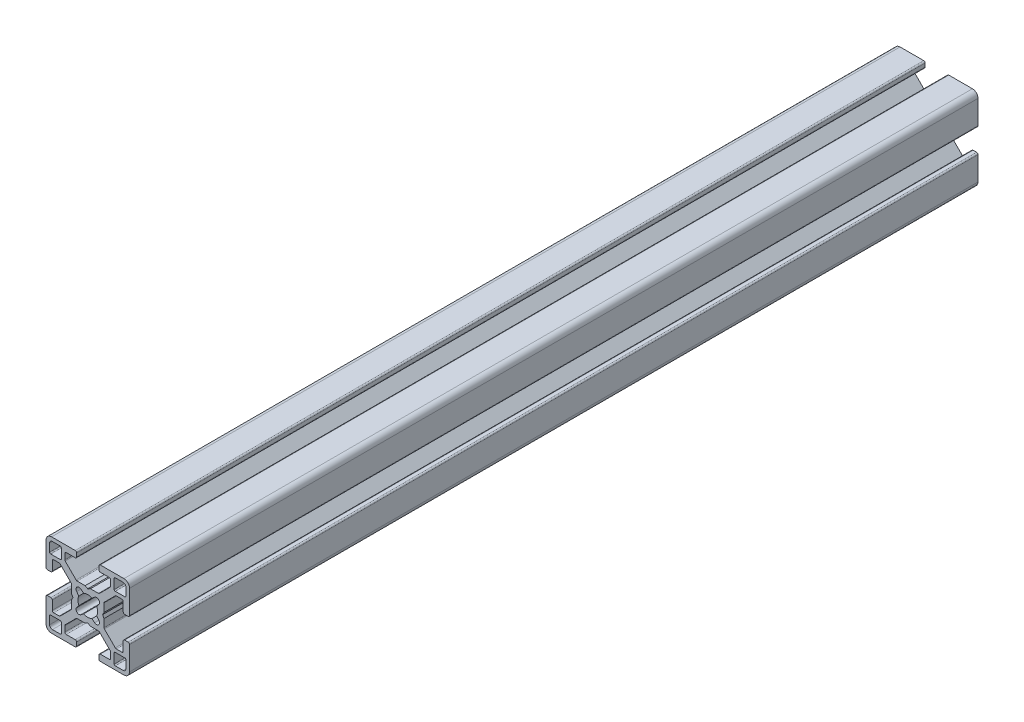
from build123d import *

# Parameters (mm, degrees)
EXTRUDE1_DEPTH = 304.8


with BuildPart() as part:
    # Sketch1 → Extrude1 (new body)
    with BuildSketch(Plane.XY):
        with BuildLine():
            Line((12.74247465, -4.5), (12.74247465, -7.732519321))
            ThreePointArc((12.74247465, -7.732519321), (12.602449697, -8.097296796), (12.242781236, -8.249967))
            Line((12.242781236, -8.249967), (10.260188032, -8.249967))
            ThreePointArc((10.260188032, -8.249967), (10.068847082, -8.211906919), (9.906636056, -8.103520976))
            Line((9.906636056, -8.103520976), (5.981117769, -4.178002689))
            ThreePointArc((5.981117769, -4.178002689), (5.872731827, -4.015791664), (5.834671745, -3.824450713))
            Line((5.834671745, -3.824450713), (5.834671745, -1.01249595))
            Line((5.834671745, -1.01249595), (5.324673785, -0.06249975))
            Line((5.324673785, -0.06249975), (5.834671745, 0.88749645))
            Line((5.834671745, 0.88749645), (5.834671745, 3.824450713))
            ThreePointArc((5.834671745, 3.824450713), (5.872731827, 4.015791664), (5.981117769, 4.178002689))
            Line((5.981117769, 4.178002689), (9.906636056, 8.103520976))
            ThreePointArc((9.906636056, 8.103520976), (10.068847082, 8.211906919), (10.260188032, 8.249967))
            Line((10.260188032, 8.249967), (12.242781236, 8.249967))
            ThreePointArc((12.242781236, 8.249967), (12.602449697, 8.097296796), (12.74247465, 7.732519321))
            Line((12.74247465, 7.732519321), (12.74247465, 4.5))
            ThreePointArc((12.74247465, 4.5), (12.88892126, 4.146446609), (13.24247465, 4))
            Line((13.24247465, 4), (14.49994, 4))
            ThreePointArc((14.49994, 4), (14.853493391, 4.146446609), (14.99994, 4.5))
            Line((14.99994, 4.5), (14.99994, 12.999948))
            ThreePointArc((14.99994, 12.999948), (14.414155906, 14.414155906), (12.999948, 14.99994))
            Line((12.999948, 14.99994), (4.5, 14.99994))
            ThreePointArc((4.5, 14.99994), (4.146446609, 14.853493391), (4, 14.49994))
            Line((4, 14.49994), (4, 13.24247465))
            ThreePointArc((4, 13.24247465), (4.146446609, 12.88892126), (4.5, 12.74247465))
            Line((4.5, 12.74247465), (7.732519321, 12.74247465))
            ThreePointArc((7.732519321, 12.74247465), (8.097296796, 12.602449697), (8.249967, 12.242781236))
            Line((8.249967, 12.242781236), (8.249967, 10.260188032))
            ThreePointArc((8.249967, 10.260188032), (8.211906919, 10.068847082), (8.103520976, 9.906636056))
            Line((8.103520976, 9.906636056), (4.178002689, 5.981117769))
            ThreePointArc((4.178002689, 5.981117769), (4.015791664, 5.872731827), (3.824450713, 5.834671745))
            Line((3.824450713, 5.834671745), (0.9499962, 5.834671745))
            Line((0.9499962, 5.834671745), (0, 5.324673785))
            Line((0, 5.324673785), (-0.9499962, 5.834671745))
            Line((-0.9499962, 5.834671745), (-3.824450713, 5.834671745))
            ThreePointArc((-3.824450713, 5.834671745), (-4.015791664, 5.872731827), (-4.178002689, 5.981117769))
            Line((-4.178002689, 5.981117769), (-8.103520976, 9.906636056))
            ThreePointArc((-8.103520976, 9.906636056), (-8.211906919, 10.068847082), (-8.249967, 10.260188032))
            Line((-8.249967, 10.260188032), (-8.249967, 12.242781236))
            ThreePointArc((-8.249967, 12.242781236), (-8.097296796, 12.602449697), (-7.732519321, 12.74247465))
            Line((-7.732519321, 12.74247465), (-4.5, 12.74247465))
            ThreePointArc((-4.5, 12.74247465), (-4.146446609, 12.88892126), (-4, 13.24247465))
            Line((-4, 13.24247465), (-4, 14.49994))
            ThreePointArc((-4, 14.49994), (-4.146446609, 14.853493391), (-4.5, 14.99994))
            Line((-4.5, 14.99994), (-12.999948, 14.99994))
            ThreePointArc((-12.999948, 14.99994), (-14.414155906, 14.414155906), (-14.99994, 12.999948))
            Line((-14.99994, 12.999948), (-14.99994, 4.5))
            ThreePointArc((-14.99994, 4.5), (-14.853493391, 4.146446609), (-14.49994, 4))
            Line((-14.49994, 4), (-13.24247465, 4))
            ThreePointArc((-13.24247465, 4), (-12.88892126, 4.146446609), (-12.74247465, 4.5))
            Line((-12.74247465, 4.5), (-12.74247465, 7.732519321))
            ThreePointArc((-12.74247465, 7.732519321), (-12.602449697, 8.097296796), (-12.242781236, 8.249967))
            Line((-12.242781236, 8.249967), (-10.260188032, 8.249967))
            ThreePointArc((-10.260188032, 8.249967), (-10.068847082, 8.211906919), (-9.906636056, 8.103520976))
            Line((-9.906636056, 8.103520976), (-5.981117769, 4.178002689))
            ThreePointArc((-5.981117769, 4.178002689), (-5.872731827, 4.015791664), (-5.834671745, 3.824450713))
            Line((-5.834671745, 3.824450713), (-5.834671745, 0.88749645))
            Line((-5.834671745, 0.88749645), (-5.324673785, -0.06249975))
            Line((-5.324673785, -0.06249975), (-5.834671745, -1.01249595))
            Line((-5.834671745, -1.01249595), (-5.834671745, -3.824450713))
            ThreePointArc((-5.834671745, -3.824450713), (-5.872731827, -4.015791664), (-5.981117769, -4.178002689))
            Line((-5.981117769, -4.178002689), (-9.906636056, -8.103520976))
            ThreePointArc((-9.906636056, -8.103520976), (-10.068847082, -8.211906919), (-10.260188032, -8.249967))
            Line((-10.260188032, -8.249967), (-12.242781236, -8.249967))
            ThreePointArc((-12.242781236, -8.249967), (-12.602449697, -8.097296796), (-12.74247465, -7.732519321))
            Line((-12.74247465, -7.732519321), (-12.74247465, -4.5))
            ThreePointArc((-12.74247465, -4.5), (-12.88892126, -4.146446609), (-13.24247465, -4))
            Line((-13.24247465, -4), (-14.49994, -4))
            ThreePointArc((-14.49994, -4), (-14.853493391, -4.146446609), (-14.99994, -4.5))
            Line((-14.99994, -4.5), (-14.99994, -12.999948))
            ThreePointArc((-14.99994, -12.999948), (-14.414155906, -14.414155906), (-12.999948, -14.99994))
            Line((-12.999948, -14.99994), (-4.5, -14.99994))
            ThreePointArc((-4.5, -14.99994), (-4.146446609, -14.853493391), (-4, -14.49994))
            Line((-4, -14.49994), (-4, -13.24247465))
            ThreePointArc((-4, -13.24247465), (-4.146446609, -12.88892126), (-4.5, -12.74247465))
            Line((-4.5, -12.74247465), (-7.732519321, -12.74247465))
            ThreePointArc((-7.732519321, -12.74247465), (-8.097296796, -12.602449697), (-8.249967, -12.242781236))
            Line((-8.249967, -12.242781236), (-8.249967, -10.260188032))
            ThreePointArc((-8.249967, -10.260188032), (-8.211906919, -10.068847082), (-8.103520976, -9.906636056))
            Line((-8.103520976, -9.906636056), (-4.178002689, -5.981117769))
            ThreePointArc((-4.178002689, -5.981117769), (-4.015791664, -5.872731827), (-3.824450713, -5.834671745))
            Line((-3.824450713, -5.834671745), (-0.9499962, -5.834671745))
            Line((-0.9499962, -5.834671745), (0, -5.324673785))
            Line((0, -5.324673785), (0.9499962, -5.834671745))
            Line((0.9499962, -5.834671745), (3.824450713, -5.834671745))
            ThreePointArc((3.824450713, -5.834671745), (4.015791664, -5.872731827), (4.178002689, -5.981117769))
            Line((4.178002689, -5.981117769), (8.103520976, -9.906636056))
            ThreePointArc((8.103520976, -9.906636056), (8.211906919, -10.068847082), (8.249967, -10.260188032))
            Line((8.249967, -10.260188032), (8.249967, -12.242781236))
            ThreePointArc((8.249967, -12.242781236), (8.097296796, -12.602449697), (7.732519321, -12.74247465))
            Line((7.732519321, -12.74247465), (4.5, -12.74247465))
            ThreePointArc((4.5, -12.74247465), (4.146446609, -12.88892126), (4, -13.24247465))
            Line((4, -13.24247465), (4, -14.49994))
            ThreePointArc((4, -14.49994), (4.146446609, -14.853493391), (4.5, -14.99994))
            Line((4.5, -14.99994), (12.999948, -14.99994))
            ThreePointArc((12.999948, -14.99994), (14.414155906, -14.414155906), (14.99994, -12.999948))
            Line((14.99994, -12.999948), (14.99994, -4.5))
            ThreePointArc((14.99994, -4.5), (14.853493391, -4.146446609), (14.49994, -4))
            Line((14.49994, -4), (13.24247465, -4))
            ThreePointArc((13.24247465, -4), (12.88892126, -4.146446609), (12.74247465, -4.5))
        make_face()
        with BuildLine():
            Line((9.499962, -13.318946724), (9.499962, -9.87996048))
            ThreePointArc((9.499962, -9.87996048), (9.611260978, -9.611260978), (9.87996048, -9.499962))
            Line((9.87996048, -9.499962), (13.318946724, -9.499962))
            ThreePointArc((13.318946724, -9.499962), (13.58835333, -9.61155387), (13.6999452, -9.880960476))
            Line((13.6999452, -9.880960476), (13.6999452, -12.6999492))
            ThreePointArc((13.6999452, -12.6999492), (13.407053153, -13.407053153), (12.6999492, -13.6999452))
            Line((12.6999492, -13.6999452), (9.880960476, -13.6999452))
            ThreePointArc((9.880960476, -13.6999452), (9.61155387, -13.58835333), (9.499962, -13.318946724))
        make_face(mode=Mode.SUBTRACT)
        with BuildLine():
            Line((-13.318946724, -9.499962), (-9.87996048, -9.499962))
            ThreePointArc((-9.87996048, -9.499962), (-9.611260978, -9.611260978), (-9.499962, -9.87996048))
            Line((-9.499962, -9.87996048), (-9.499962, -13.318946724))
            ThreePointArc((-9.499962, -13.318946724), (-9.61155387, -13.58835333), (-9.880960476, -13.6999452))
            Line((-9.880960476, -13.6999452), (-12.6999492, -13.6999452))
            ThreePointArc((-12.6999492, -13.6999452), (-13.407053153, -13.407053153), (-13.6999452, -12.6999492))
            Line((-13.6999452, -12.6999492), (-13.6999452, -9.880960476))
            ThreePointArc((-13.6999452, -9.880960476), (-13.58835333, -9.61155387), (-13.318946724, -9.499962))
        make_face(mode=Mode.SUBTRACT)
        with BuildLine():
            Line((-1.494225248, -3.198138712), (-2.473341823, -3.979927146))
            ThreePointArc((-2.473341823, -3.979927146), (-3.900227701, -3.900227701), (-3.979927146, -2.473341823))
            Line((-3.979927146, -2.473341823), (-3.198138712, -1.494225248))
            ThreePointArc((-3.198138712, -1.494225248), (-3.52998588, 0), (-3.198138712, 1.494225248))
            Line((-3.198138712, 1.494225248), (-3.979927146, 2.473341823))
            ThreePointArc((-3.979927146, 2.473341823), (-3.900227701, 3.900227701), (-2.473341823, 3.979927146))
            Line((-2.473341823, 3.979927146), (-1.494225248, 3.198138712))
            ThreePointArc((-1.494225248, 3.198138712), (0, 3.52998588), (1.494225248, 3.198138712))
            Line((1.494225248, 3.198138712), (2.473341823, 3.979927146))
            ThreePointArc((2.473341823, 3.979927146), (3.900227701, 3.900227701), (3.979927146, 2.473341823))
            Line((3.979927146, 2.473341823), (3.198138712, 1.494225248))
            ThreePointArc((3.198138712, 1.494225248), (3.52998588, 0), (3.198138712, -1.494225248))
            Line((3.198138712, -1.494225248), (3.979927146, -2.473341823))
            ThreePointArc((3.979927146, -2.473341823), (3.900227701, -3.900227701), (2.473341823, -3.979927146))
            Line((2.473341823, -3.979927146), (1.494225248, -3.198138712))
            ThreePointArc((1.494225248, -3.198138712), (0, -3.52998588), (-1.494225248, -3.198138712))
        make_face(mode=Mode.SUBTRACT)
        with BuildLine():
            Line((-9.499962, 13.318946724), (-9.499962, 9.87996048))
            ThreePointArc((-9.499962, 9.87996048), (-9.611260978, 9.611260978), (-9.87996048, 9.499962))
            Line((-9.87996048, 9.499962), (-13.318946724, 9.499962))
            ThreePointArc((-13.318946724, 9.499962), (-13.58835333, 9.61155387), (-13.6999452, 9.880960476))
            Line((-13.6999452, 9.880960476), (-13.6999452, 12.6999492))
            ThreePointArc((-13.6999452, 12.6999492), (-13.407053153, 13.407053153), (-12.6999492, 13.6999452))
            Line((-12.6999492, 13.6999452), (-9.880960476, 13.6999452))
            ThreePointArc((-9.880960476, 13.6999452), (-9.61155387, 13.58835333), (-9.499962, 13.318946724))
        make_face(mode=Mode.SUBTRACT)
        with BuildLine():
            Line((9.880960476, 13.6999452), (12.6999492, 13.6999452))
            ThreePointArc((12.6999492, 13.6999452), (13.407053153, 13.407053153), (13.6999452, 12.6999492))
            Line((13.6999452, 12.6999492), (13.6999452, 9.880960476))
            ThreePointArc((13.6999452, 9.880960476), (13.58835333, 9.61155387), (13.318946724, 9.499962))
            Line((13.318946724, 9.499962), (9.87996048, 9.499962))
            ThreePointArc((9.87996048, 9.499962), (9.611260978, 9.611260978), (9.499962, 9.87996048))
            Line((9.499962, 9.87996048), (9.499962, 13.318946724))
            ThreePointArc((9.499962, 13.318946724), (9.61155387, 13.58835333), (9.880960476, 13.6999452))
        make_face(mode=Mode.SUBTRACT)
    extrude(amount=-EXTRUDE1_DEPTH)


solid = part.part
